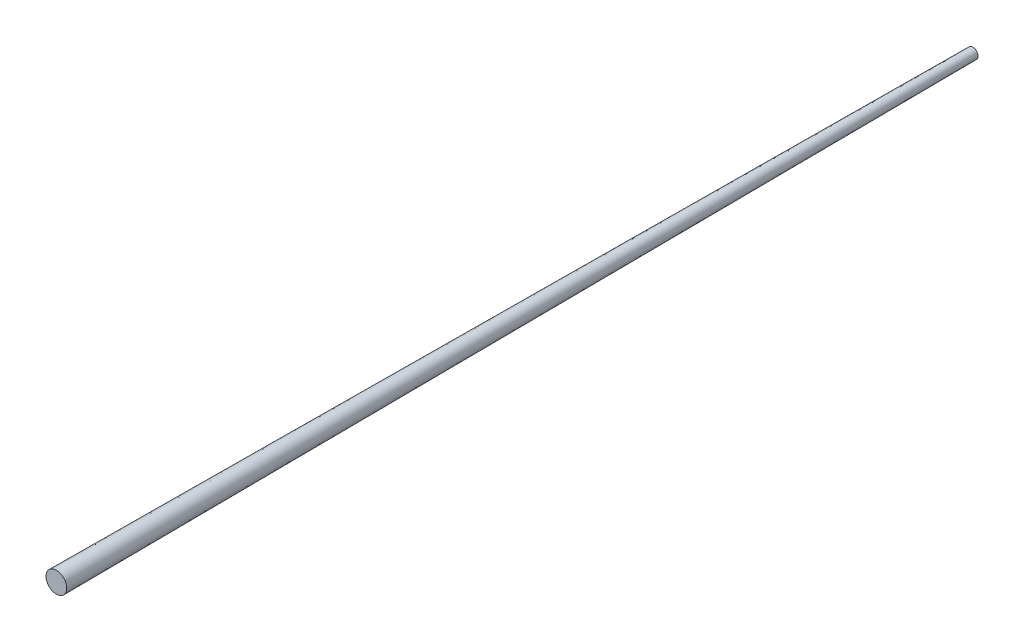
from build123d import *


with BuildPart() as part:
    # Sketch1 → Revolve1 (revolve)
    with BuildSketch(Plane(origin=(0, 0, 0), x_dir=(1, 0, 0), z_dir=(0, 1, 0))):
        Polygon((2.02, 355.6), (0, 355.6), (0, 0), (4.02, 0), align=None)
    revolve(axis=Axis((0, 0, -355.6), (0, 0, 1)))


solid = part.part
